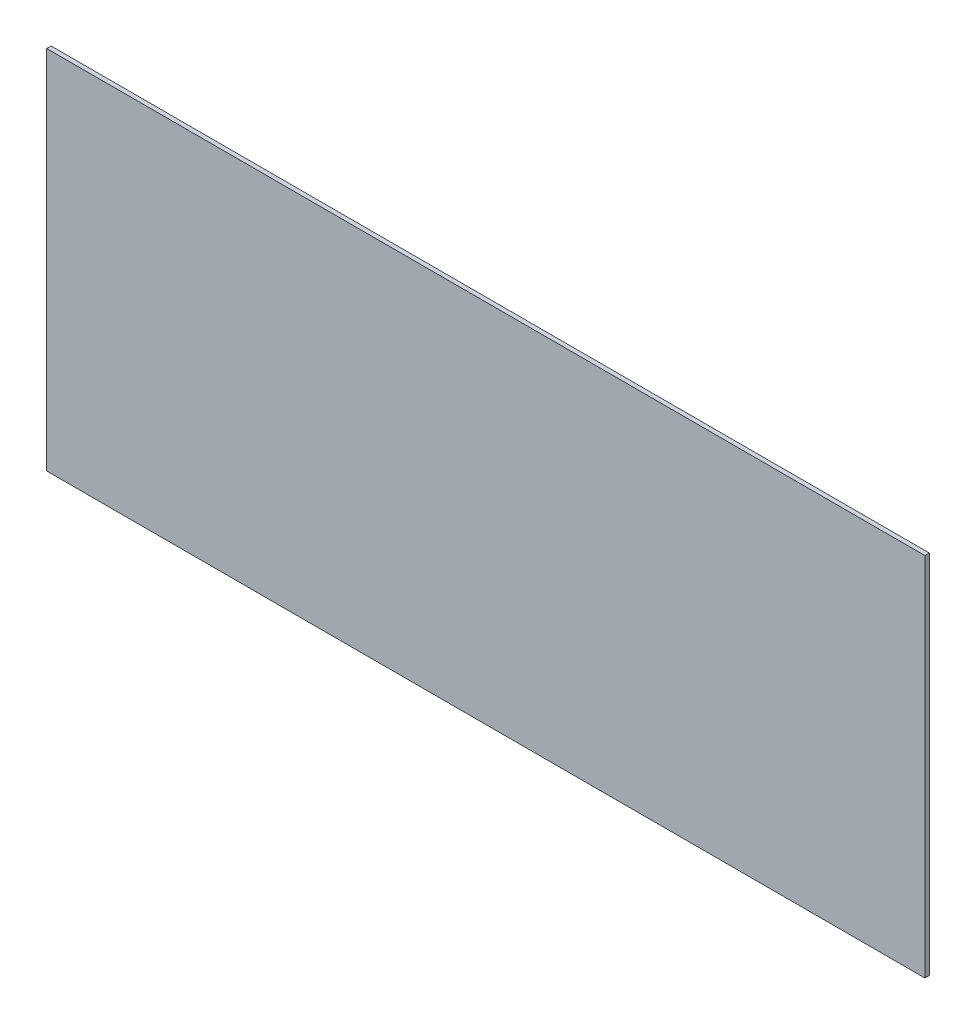
from build123d import *

# Parameters (mm, degrees)
SKETCH_1_W      = 600
SKETCH_1_H      = 3
EXTRUDE_1_DEPTH = 250


with BuildPart() as part:
    # 스케치1 → 보스-돌출1 (new body)
    with BuildSketch(Plane(origin=(0, 0, 0), x_dir=(1, 0, 0), z_dir=(0, 1, 0))):
        with Locations((300, 1.5)):
            Rectangle(SKETCH_1_W, SKETCH_1_H)
    extrude(amount=EXTRUDE_1_DEPTH)


solid = part.part
